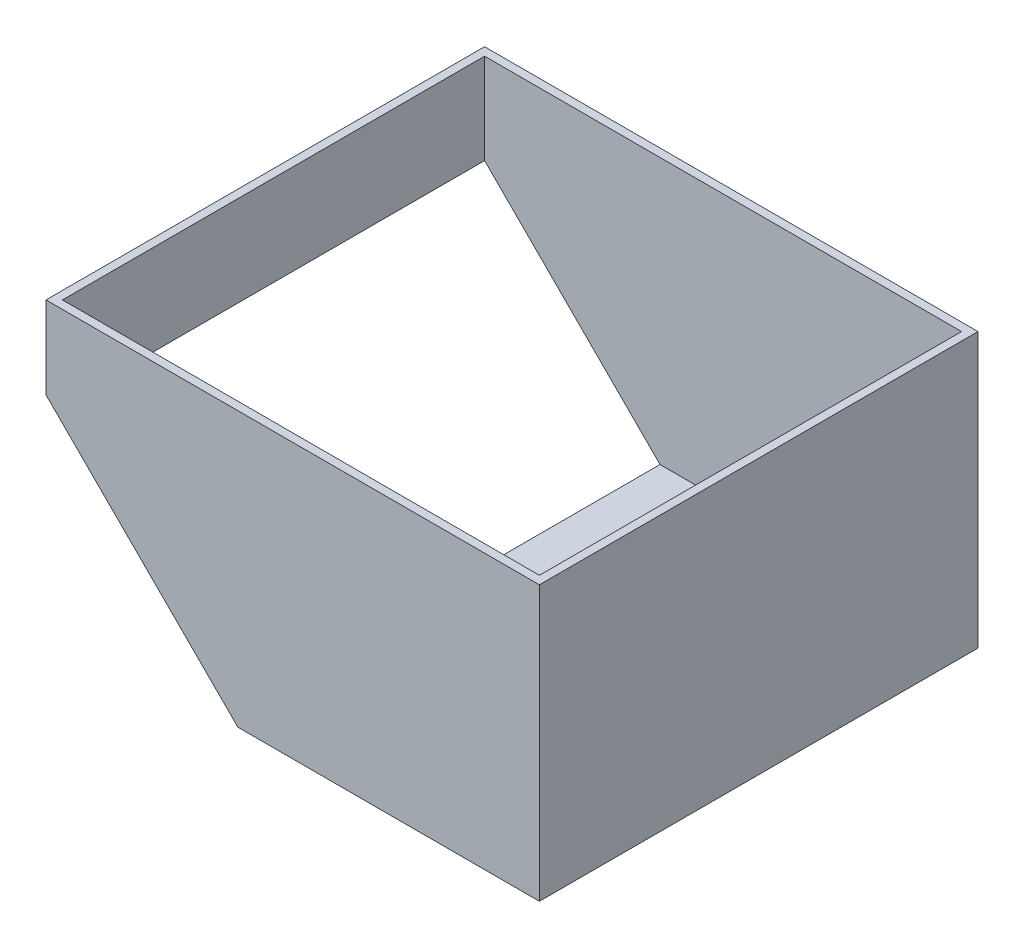
from build123d import *

# Parameters (mm, degrees)
SKETCH1_W               = 180
SKETCH1_H               = 160
BOSS_EXTRUDE1_DEPTH     = 3
SKETCH2_W               = 180
SKETCH2_H               = 160
SKETCH2_W_2             = 174
SKETCH2_H_2             = 154
BOSS_EXTRUDE2_DEPTH     = 100
CUT_EXTRUDE1_DEPTH      = 1
CUT_EXTRUDE1_DEPTH_BACK = 161


with BuildPart() as part:
    # Sketch1 → Boss-Extrude1 (new body)
    with BuildSketch(Plane(origin=(0, 0, 0), x_dir=(1, 0, 0), z_dir=(0, 1, 0))):
        with Locations((90, 80)):
            Rectangle(SKETCH1_W, SKETCH1_H)
    extrude(amount=BOSS_EXTRUDE1_DEPTH)

    # Sketch2 → Boss-Extrude2 (add)
    with BuildSketch(Plane(origin=(0, 0, 0), x_dir=(1, 0, 0), z_dir=(0, 1, 0))):
        with Locations((90, 80)):
            Rectangle(SKETCH2_W, SKETCH2_H)
        with Locations((90, 80)):
            Rectangle(SKETCH2_W_2, SKETCH2_H_2, mode=Mode.SUBTRACT)
    extrude(amount=BOSS_EXTRUDE2_DEPTH)

    # Sketch3 → Cut-Extrude1 (cut, two sides)
    with BuildSketch(Plane.XY) as cut_extrude1_sk:
        Polygon((0, 70), (70, 0), (0, 0), align=None)
    extrude(amount=CUT_EXTRUDE1_DEPTH, mode=Mode.SUBTRACT)
    extrude(cut_extrude1_sk.sketch, amount=-CUT_EXTRUDE1_DEPTH_BACK, mode=Mode.SUBTRACT)


solid = part.part
